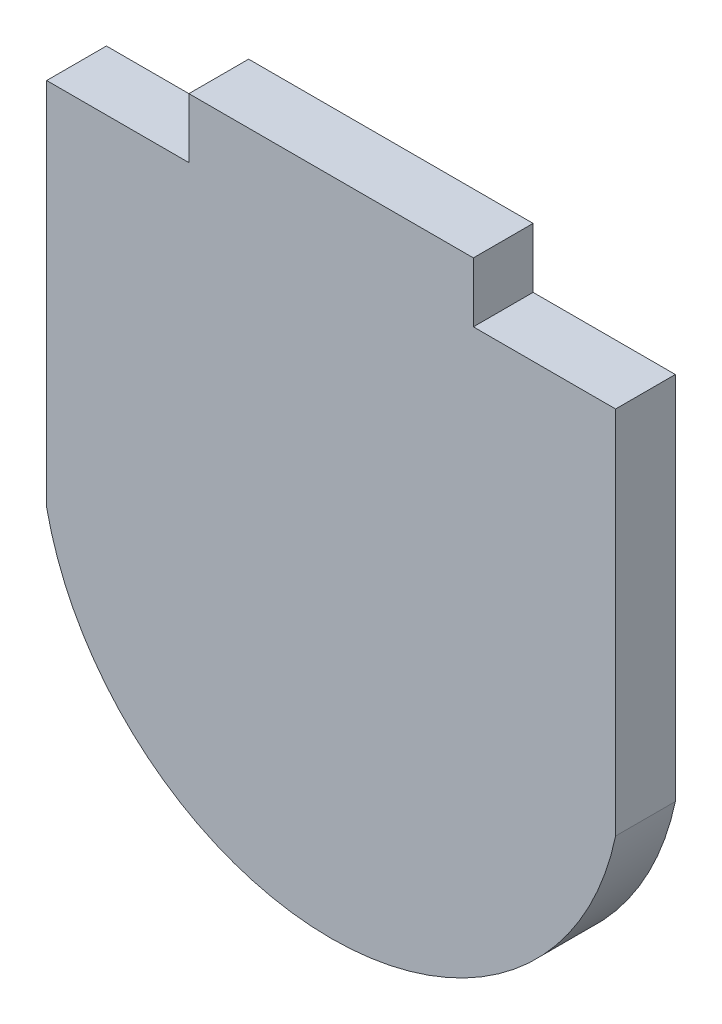
from build123d import *

# Parameters (mm, degrees)
BOSS_EXTRUDE1_DEPTH = 5.334
SKETCH2_W           = 12.7
SKETCH2_H           = 5.334
CUT_EXTRUDE1_DEPTH  = 6.334


with BuildPart() as part:
    # Sketch1 → Boss-Extrude1 (new body)
    with BuildSketch(Plane.XY):
        with BuildLine():
            Line((-38.121026248, 59.736005595), (-38.121026248, 98.090005595))
            Line((-38.121026248, 98.090005595), (12.678973752, 98.090005595))
            Line((12.678973752, 98.090005595), (12.678973752, 59.736005595))
            ThreePointArc((12.678973752, 59.736005595), (-12.721026248, 39.115977854), (-38.121026248, 59.736005595))
        make_face()
    extrude(amount=BOSS_EXTRUDE1_DEPTH)

    # Sketch2 → Cut-Extrude1 (cut, through all)
    with BuildSketch(Plane.XY.offset(5.334)):
        with Locations((-31.771026248, 95.423005595)):
            Rectangle(SKETCH2_W, SKETCH2_H)
        with Locations((6.328973752, 95.423005595)):
            Rectangle(SKETCH2_W, SKETCH2_H)
    extrude(amount=-CUT_EXTRUDE1_DEPTH, mode=Mode.SUBTRACT)


solid = part.part
